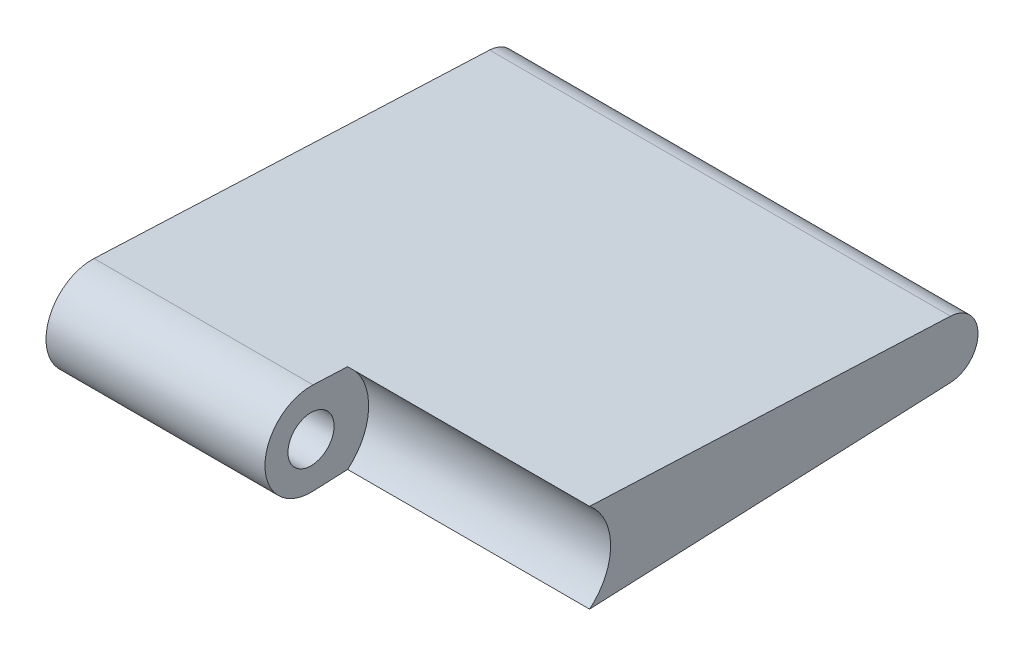
from build123d import *

# Parameters (mm, degrees)
SKETCH1_R           = 0.78486
BOSS_EXTRUDE1_DEPTH = 15.68196
SKETCH2_R           = 1.96088
CUT_EXTRUDE1_DEPTH  = 8.23214


with BuildPart() as part:
    # Sketch1 → Boss-Extrude1 (new body)
    with BuildSketch(Plane(origin=(0, 0, 0), x_dir=(0, 0, -1), z_dir=(1, 0, 0))):
        with BuildLine():
            Line((-6.346883091, -1.565695238), (7.109902444, -0.979511121))
            ThreePointArc((7.109902444, -0.979511121), (8.047674463, 0), (7.109902444, 0.979511121))
            Line((7.109902444, 0.979511121), (-6.346883091, 1.565695238))
            ThreePointArc((-6.346883091, 1.565695238), (-7.982265537, 0), (-6.346883091, -1.565695238))
        make_face()
        with Locations((-6.415085537, 0)):
            Circle(SKETCH1_R, mode=Mode.SUBTRACT)
    extrude(amount=-BOSS_EXTRUDE1_DEPTH)

    # Sketch2 → Cut-Extrude1 (cut)
    with BuildSketch(Plane(origin=(0, 0, 0), x_dir=(0, 0, -1), z_dir=(1, 0, 0))):
        with Locations((-6.415085537, 0)):
            Circle(SKETCH2_R)
    extrude(amount=-CUT_EXTRUDE1_DEPTH, mode=Mode.SUBTRACT)


solid = part.part
